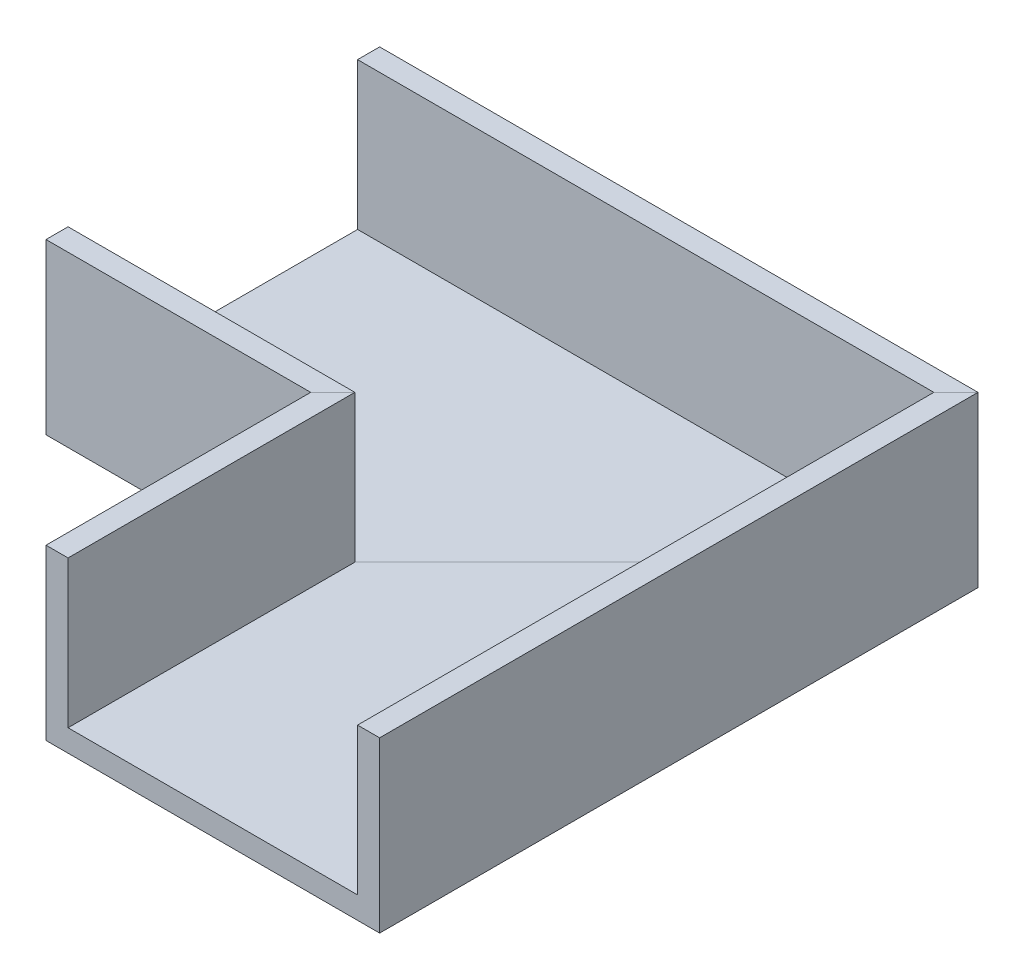
from build123d import *


with BuildPart() as part:
    # Sweep1: sweep along a path in Sketch1
    with BuildLine(Plane(origin=(0, 0, 0), x_dir=(1, 0, 0), z_dir=(0, 1, 0))) as sweep1_path:
        Line((0, 0), (0, 36))
        Line((0, 36), (-36, 36))
    # Sketch2 → Sweep1 (sweep)
    with BuildSketch(Plane.XY):
        Polygon((0, 0), (0, 23), (3, 23), (3, 3), (42.37, 3), (42.37, 23), (45.37, 23), (45.37, 0), align=None)
    sweep(path=sweep1_path.line, transition=Transition.RIGHT)


solid = part.part
